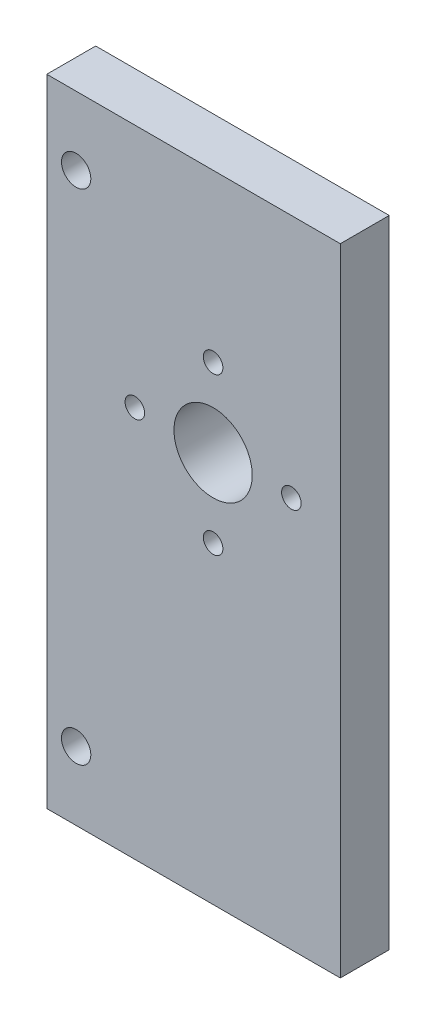
from build123d import *

# Parameters (mm, degrees)
ESQUISSE1_W             = 30
ESQUISSE1_H             = 65
ESQUISSE1_R             = 1.5
ESQUISSE1_R_2           = 1
ESQUISSE1_R_3           = 4
BOSS_EXTRU_1_DEPTH      = 6
ESQUISSE5_W             = 30
ESQUISSE5_H             = 65
ESQUISSE5_R             = 10.5
ENL_V_MAT_EXTRU_4_DEPTH = 1


with BuildPart() as part:
    # Esquisse1 → Boss.-Extru.1 (new body)
    with BuildSketch(Plane.XY):
        with Locations((40.364568032, -83.170745263)):
            Rectangle(ESQUISSE1_W, ESQUISSE1_H)
        with Locations((28.364568032, -57.670745263)):
            Circle(ESQUISSE1_R, mode=Mode.SUBTRACT)
        with Locations((28.364568032, -108.670745263)):
            Circle(ESQUISSE1_R, mode=Mode.SUBTRACT)
        with Locations((34.364568032, -75.670745263)):
            Circle(ESQUISSE1_R_2, mode=Mode.SUBTRACT)
        with Locations((42.364568032, -67.670745263)):
            Circle(ESQUISSE1_R_2, mode=Mode.SUBTRACT)
        with Locations((50.364568032, -75.670745263)):
            Circle(ESQUISSE1_R_2, mode=Mode.SUBTRACT)
        with Locations((42.364568032, -83.670745263)):
            Circle(ESQUISSE1_R_2, mode=Mode.SUBTRACT)
        with Locations((42.364568032, -75.670745263)):
            Circle(ESQUISSE1_R_3, mode=Mode.SUBTRACT)
    extrude(amount=BOSS_EXTRU_1_DEPTH)

    # Esquisse5 → Enlèv. mat.-Extru.4 (cut)
    with BuildSketch(Plane(origin=(0, 0, 0), x_dir=(-1, 0, 0), z_dir=(0, 0, -1))):
        with Locations((-40.364568032, -83.170745263)):
            Rectangle(ESQUISSE5_W, ESQUISSE5_H)
        with Locations((-42.364568032, -75.670745263)):
            Circle(ESQUISSE5_R, mode=Mode.SUBTRACT)
    extrude(amount=-ENL_V_MAT_EXTRU_4_DEPTH, mode=Mode.SUBTRACT)


solid = part.part
